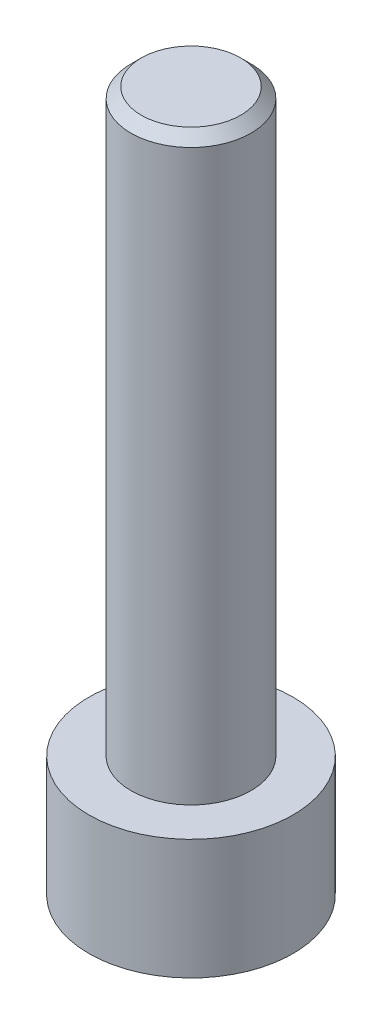
from build123d import *

# Parameters (mm, degrees)
SKETCH1_R           = 2.465
BOSS_EXTRUDE1_DEPTH = 2.9
SKETCH2_R           = 1.45
BOSS_EXTRUDE2_DEPTH = 14
CUT_EXTRUDE1_DEPTH  = 1.9
CHAMFER1_SIZE       = 0.25


with BuildPart() as part:
    # Sketch1 → Boss-Extrude1 (new body)
    with BuildSketch(Plane(origin=(0, 0, 0), x_dir=(1, 0, 0), z_dir=(0, 1, 0))):
        Circle(SKETCH1_R)
    extrude(amount=BOSS_EXTRUDE1_DEPTH)

    # Sketch2 → Boss-Extrude2 (add)
    with BuildSketch(Plane(origin=(0, 2.9, 0), x_dir=(1, 0, 0), z_dir=(0, 1, 0))):
        Circle(SKETCH2_R)
    extrude(amount=BOSS_EXTRUDE2_DEPTH)

    # Sketch3 → Cut-Extrude1 (cut)
    with BuildSketch(Plane.XZ):
        Polygon((0.733234842, -1.27), (1.466469684, 0), (0.733234842, 1.27), (-0.733234842, 1.27), (-1.466469684, 0), (-0.733234842, -1.27), align=None)
    extrude(amount=-CUT_EXTRUDE1_DEPTH, mode=Mode.SUBTRACT)

    # Chamfer1
    chamfer1_edges = [part.edges().sort_by_distance(p)[0] for p in [
        (-1.45, 16.9, 0),
    ]]
    chamfer(chamfer1_edges, length=CHAMFER1_SIZE)


solid = part.part
